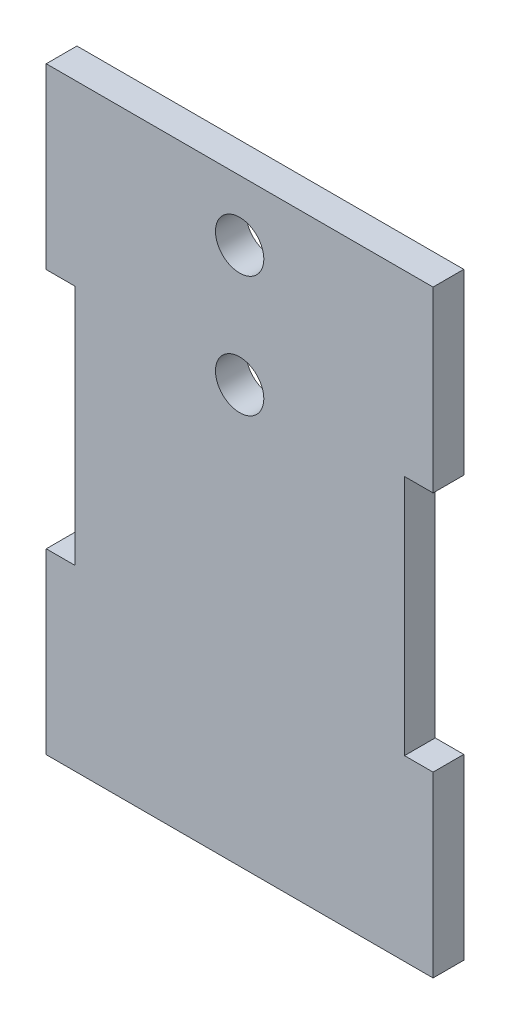
from build123d import *

# Parameters (mm, degrees)
SKETCH1_R           = 2
BOSS_EXTRUDE1_DEPTH = 2.54


with BuildPart() as part:
    # Sketch1 → Boss-Extrude1 (new body)
    with BuildSketch(Plane.XY):
        Polygon((-16, -24.75), (16, -24.75), (16, -10), (13.64, -10), (13.64, 10), (16, 10), (16, 24.75), (-16, 24.75), (-16, 10), (-13.64, 10), (-13.64, -10), (-16, -10), align=None)
        with Locations((0, 9.75)):
            Circle(SKETCH1_R, mode=Mode.SUBTRACT)
        with Locations((0, 19.75)):
            Circle(SKETCH1_R, mode=Mode.SUBTRACT)
    extrude(amount=BOSS_EXTRUDE1_DEPTH)


solid = part.part
